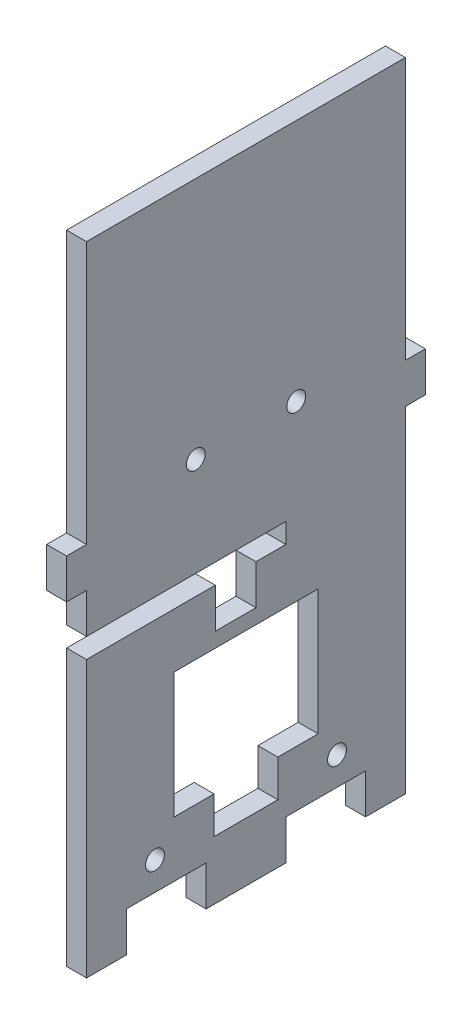
from build123d import *

# Parameters (mm, degrees)
SKETCH1_W              = 273.05
SKETCH1_H              = 139.7
BOSS_EXTRUDE1_DEPTH    = 6.35
SKETCH2_W              = 273.05
SKETCH2_H              = 139.7
SKETCH2_W_2            = 266.7
SKETCH2_H_2            = 133.35
BOSS_EXTRUDE2_DEPTH    = 298.45
SKETCH3_W              = 6.35
SKETCH3_H              = 16.933333333
SKETCH3_H_2            = 16.933333334
DOOR_SLOT_DEPTH        = 12.7
DOOR_GUIDE_HOLES_REACH = 362.806
SKETCH4_W              = 6.35
SKETCH4_H              = 15.875
LEVER_HOLES_W          = 9.652
LEVER_HOLES_H          = 6.35
LEVER_HOLES_W_2        = 6.35
CUT_EXTRUDE1_DEPTH     = 363.019620497
CUT_EXTRUDE3_REACH     = 417.137
SKETCH8_R              = 3.175
SKETCH16_W             = 329.651778096
SKETCH16_H             = 315.233565403
CUT_EXTRUDE10_DEPTH    = 363.019620497
LEFT_RIGHT_W           = 9.525
LEFT_RIGHT_H           = 6.35
LEFT_RIGHT_W_2         = 12.7
LEFT_RIGHT_W_3         = 3.175
LEFT_RIGHT_H_2         = 12.7
CUT_EXTRUDE11_DEPTH    = 416.136561869
SKETCH17_W             = 23
SKETCH17_H             = 20.0007988
SKETCH17_W_2           = 10.16
SKETCH17_H_2           = 5.89
SKETCH17_R             = 1.5
CUT_EXTRUDE12_DEPTH    = 313.717353412
CUT_EXTRUDE13_DEPTH    = 313.717353412
CUT_EXTRUDE14_DEPTH    = 106.589636092


with BuildPart() as part:
    # Sketch1 → Boss-Extrude1 (new body)
    with BuildSketch(Plane(origin=(0, 0, 0), x_dir=(1, 0, 0), z_dir=(0, 1, 0))):
        Rectangle(SKETCH1_W, SKETCH1_H)
    extrude(amount=BOSS_EXTRUDE1_DEPTH)

    # Sketch2 → Boss-Extrude2 (add)
    with BuildSketch(Plane(origin=(0, 6.35, 0), x_dir=(1, 0, 0), z_dir=(0, 1, 0))):
        Rectangle(SKETCH2_W, SKETCH2_H)
        Rectangle(SKETCH2_W_2, SKETCH2_H_2, mode=Mode.SUBTRACT)
    extrude(amount=BOSS_EXTRUDE2_DEPTH)

    # Sketch3 → Door Slot (cut)
    with BuildSketch(Plane.XY.offset(69.85)):
        with BuildLine():
            Line((-31.75, 283.21), (-31.75, 6.35))
            Line((-31.75, 6.35), (-25.146, 6.35))
            Line((-25.146, 6.35), (-25.146, 292.354))
            Line((-25.146, 292.354), (-44.704, 292.354))
            Line((-44.704, 292.354), (-44.704, 285.75))
            Line((-44.704, 285.75), (-34.29, 285.75))
            ThreePointArc((-34.29, 285.75), (-32.493948776, 285.006051224), (-31.75, 283.21))
        make_face()
        with Locations((-15.621, 80.433333334)):
            Rectangle(SKETCH3_W, SKETCH3_H)
        with Locations((-15.621, 50.8)):
            Rectangle(SKETCH3_W, SKETCH3_H_2)
        with Locations((-15.621, 21.166666667)):
            Rectangle(SKETCH3_W, SKETCH3_H)
    extrude(amount=-DOOR_SLOT_DEPTH, mode=Mode.SUBTRACT)

    # Sketch4 → Door Guide Holes (cut, up to next)
    with BuildSketch(Plane.XY.offset(-66.675), mode=Mode.PRIVATE) as door_guide_holes_sk1:
        with Locations((-47.879, 284.1625)):
            Rectangle(SKETCH4_W, SKETCH4_H)
    door_guide_holes_tool1 = extrude(door_guide_holes_sk1.sketch, amount=-DOOR_GUIDE_HOLES_REACH, mode=Mode.PRIVATE) & part.part
    # Sketch4 → Door Guide Holes (cut, up to next)
    with BuildSketch(Plane.XY.offset(-66.675), mode=Mode.PRIVATE) as door_guide_holes_sk2:
        with Locations((-47.879, 255.5875)):
            Rectangle(SKETCH4_W, SKETCH4_H)
    door_guide_holes_tool2 = extrude(door_guide_holes_sk2.sketch, amount=-DOOR_GUIDE_HOLES_REACH, mode=Mode.PRIVATE) & part.part
    # Sketch4 → Door Guide Holes (cut, up to next)
    with BuildSketch(Plane.XY.offset(-66.675), mode=Mode.PRIVATE) as door_guide_holes_sk3:
        with Locations((-47.879, 227.0125)):
            Rectangle(SKETCH4_W, SKETCH4_H)
    door_guide_holes_tool3 = extrude(door_guide_holes_sk3.sketch, amount=-DOOR_GUIDE_HOLES_REACH, mode=Mode.PRIVATE) & part.part
    # Sketch4 → Door Guide Holes (cut, up to next)
    with BuildSketch(Plane.XY.offset(-66.675), mode=Mode.PRIVATE) as door_guide_holes_sk4:
        with Locations((-47.879, 198.4375)):
            Rectangle(SKETCH4_W, SKETCH4_H)
    door_guide_holes_tool4 = extrude(door_guide_holes_sk4.sketch, amount=-DOOR_GUIDE_HOLES_REACH, mode=Mode.PRIVATE) & part.part
    # Sketch4 → Door Guide Holes (cut, up to next)
    with BuildSketch(Plane.XY.offset(-66.675), mode=Mode.PRIVATE) as door_guide_holes_sk5:
        with Locations((-47.879, 169.8625)):
            Rectangle(SKETCH4_W, SKETCH4_H)
    door_guide_holes_tool5 = extrude(door_guide_holes_sk5.sketch, amount=-DOOR_GUIDE_HOLES_REACH, mode=Mode.PRIVATE) & part.part
    # Sketch4 → Door Guide Holes (cut, up to next)
    with BuildSketch(Plane.XY.offset(-66.675), mode=Mode.PRIVATE) as door_guide_holes_sk6:
        with Locations((-47.879, 141.2875)):
            Rectangle(SKETCH4_W, SKETCH4_H)
    door_guide_holes_tool6 = extrude(door_guide_holes_sk6.sketch, amount=-DOOR_GUIDE_HOLES_REACH, mode=Mode.PRIVATE) & part.part
    # Sketch4 → Door Guide Holes (cut, up to next)
    with BuildSketch(Plane.XY.offset(-66.675), mode=Mode.PRIVATE) as door_guide_holes_sk7:
        with Locations((-47.879, 112.7125)):
            Rectangle(SKETCH4_W, SKETCH4_H)
    door_guide_holes_tool7 = extrude(door_guide_holes_sk7.sketch, amount=-DOOR_GUIDE_HOLES_REACH, mode=Mode.PRIVATE) & part.part
    # Sketch4 → Door Guide Holes (cut, up to next)
    with BuildSketch(Plane.XY.offset(-66.675), mode=Mode.PRIVATE) as door_guide_holes_sk8:
        with Locations((-47.879, 84.1375)):
            Rectangle(SKETCH4_W, SKETCH4_H)
    door_guide_holes_tool8 = extrude(door_guide_holes_sk8.sketch, amount=-DOOR_GUIDE_HOLES_REACH, mode=Mode.PRIVATE) & part.part
    # Sketch4 → Door Guide Holes (cut, up to next)
    with BuildSketch(Plane.XY.offset(-66.675), mode=Mode.PRIVATE) as door_guide_holes_sk9:
        with Locations((-47.879, 55.5625)):
            Rectangle(SKETCH4_W, SKETCH4_H)
    door_guide_holes_tool9 = extrude(door_guide_holes_sk9.sketch, amount=-DOOR_GUIDE_HOLES_REACH, mode=Mode.PRIVATE) & part.part
    # Sketch4 → Door Guide Holes (cut, up to next)
    with BuildSketch(Plane.XY.offset(-66.675), mode=Mode.PRIVATE) as door_guide_holes_sk10:
        with Locations((-47.879, 26.9875)):
            Rectangle(SKETCH4_W, SKETCH4_H)
    door_guide_holes_tool10 = extrude(door_guide_holes_sk10.sketch, amount=-DOOR_GUIDE_HOLES_REACH, mode=Mode.PRIVATE) & part.part
    door_guide_holes_1 = door_guide_holes_tool1.solids().sort_by_distance((-47.879, 284.1625, -66.675))[0]
    add(door_guide_holes_1, mode=Mode.SUBTRACT)
    door_guide_holes_2 = door_guide_holes_tool2.solids().sort_by_distance((-47.879, 255.5875, -66.675))[0]
    add(door_guide_holes_2, mode=Mode.SUBTRACT)
    door_guide_holes_3 = door_guide_holes_tool3.solids().sort_by_distance((-47.879, 227.0125, -66.675))[0]
    add(door_guide_holes_3, mode=Mode.SUBTRACT)
    door_guide_holes_4 = door_guide_holes_tool4.solids().sort_by_distance((-47.879, 198.4375, -66.675))[0]
    add(door_guide_holes_4, mode=Mode.SUBTRACT)
    door_guide_holes_5 = door_guide_holes_tool5.solids().sort_by_distance((-47.879, 169.8625, -66.675))[0]
    add(door_guide_holes_5, mode=Mode.SUBTRACT)
    door_guide_holes_6 = door_guide_holes_tool6.solids().sort_by_distance((-47.879, 141.2875, -66.675))[0]
    add(door_guide_holes_6, mode=Mode.SUBTRACT)
    door_guide_holes_7 = door_guide_holes_tool7.solids().sort_by_distance((-47.879, 112.7125, -66.675))[0]
    add(door_guide_holes_7, mode=Mode.SUBTRACT)
    door_guide_holes_8 = door_guide_holes_tool8.solids().sort_by_distance((-47.879, 84.1375, -66.675))[0]
    add(door_guide_holes_8, mode=Mode.SUBTRACT)
    door_guide_holes_9 = door_guide_holes_tool9.solids().sort_by_distance((-47.879, 55.5625, -66.675))[0]
    add(door_guide_holes_9, mode=Mode.SUBTRACT)
    door_guide_holes_10 = door_guide_holes_tool10.solids().sort_by_distance((-47.879, 26.9875, -66.675))[0]
    add(door_guide_holes_10, mode=Mode.SUBTRACT)
    door_guide_holes = door_guide_holes_1 + door_guide_holes_2 + door_guide_holes_3 + door_guide_holes_4 + door_guide_holes_5 + door_guide_holes_6 + door_guide_holes_7 + door_guide_holes_8 + door_guide_holes_9 + door_guide_holes_10  # Door Guide Holes as one shape, for the pattern or mirror that repeats it

    # Mirror1: Door Guide Holes across plane
    add(door_guide_holes.mirror(Plane.ZY.offset(34.925)), mode=Mode.SUBTRACT)

    # Lever Holes → Cut-Extrude1 (cut, through all)
    with BuildSketch(Plane.XY.offset(69.85)):
        with Locations((54.102, 28.575)):
            Rectangle(LEVER_HOLES_W, LEVER_HOLES_H)
        with Locations((39.3065, 15.875)):
            Rectangle(LEVER_HOLES_W_2, LEVER_HOLES_H)
        with Locations((68.8975, 15.875)):
            Rectangle(LEVER_HOLES_W_2, LEVER_HOLES_H)
    extrude(amount=-CUT_EXTRUDE1_DEPTH, mode=Mode.SUBTRACT)

    # Sketch8 → Cut-Extrude3 (cut, up to next)
    with BuildSketch(Plane.ZY.offset(136.525), mode=Mode.PRIVATE) as cut_extrude3_sk1:
        with Locations((0, 19.05)):
            Circle(SKETCH8_R)
    cut_extrude3_tool1 = extrude(cut_extrude3_sk1.sketch, amount=-CUT_EXTRUDE3_REACH, mode=Mode.PRIVATE) & part.part
    add(cut_extrude3_tool1.solids().sort_by_distance((-136.525, 19.05, 0))[0], mode=Mode.SUBTRACT)

    # Sketch16 → Cut-Extrude10 (cut, through all)
    with BuildSketch(Plane.XY.offset(69.85)):
        with Locations((-31.475889048, 147.183217299)):
            Rectangle(SKETCH16_W, SKETCH16_H)
    extrude(amount=-CUT_EXTRUDE10_DEPTH, mode=Mode.SUBTRACT)

    # Left/Right → Cut-Extrude11 (cut, through all)
    with BuildSketch(Plane.ZY.offset(136.525)):
        with Locations((61.9125, 3.175)):
            Rectangle(LEFT_RIGHT_W, LEFT_RIGHT_H)
        with Locations((38.1, 3.175)):
            Rectangle(LEFT_RIGHT_W_2, LEFT_RIGHT_H)
        with Locations((68.2625, 19.05)):
            Rectangle(LEFT_RIGHT_W_3, LEFT_RIGHT_H_2)
        with Locations((12.7, 3.175)):
            Rectangle(LEFT_RIGHT_W_2, LEFT_RIGHT_H)
        with Locations((68.2625, 44.45)):
            Rectangle(LEFT_RIGHT_W_3, LEFT_RIGHT_H_2)
        with Locations((-12.7, 3.175)):
            Rectangle(LEFT_RIGHT_W_2, LEFT_RIGHT_H)
        with Locations((68.2625, 69.85)):
            Rectangle(LEFT_RIGHT_W_3, LEFT_RIGHT_H_2)
        with Locations((-38.1, 3.175)):
            Rectangle(LEFT_RIGHT_W_2, LEFT_RIGHT_H)
        with Locations((68.2625, 95.25)):
            Rectangle(LEFT_RIGHT_W_3, LEFT_RIGHT_H_2)
        with Locations((-61.9125, 3.175)):
            Rectangle(LEFT_RIGHT_W, LEFT_RIGHT_H)
        with Locations((68.2625, 120.65)):
            Rectangle(LEFT_RIGHT_W_3, LEFT_RIGHT_H_2)
        with Locations((-68.2625, 19.05)):
            Rectangle(LEFT_RIGHT_W_3, LEFT_RIGHT_H_2)
        with Locations((68.2625, 146.05)):
            Rectangle(LEFT_RIGHT_W_3, LEFT_RIGHT_H_2)
        with Locations((-68.2625, 44.45)):
            Rectangle(LEFT_RIGHT_W_3, LEFT_RIGHT_H_2)
        with Locations((68.2625, 171.45)):
            Rectangle(LEFT_RIGHT_W_3, LEFT_RIGHT_H_2)
        with Locations((-68.2625, 69.85)):
            Rectangle(LEFT_RIGHT_W_3, LEFT_RIGHT_H_2)
        with Locations((68.2625, 196.85)):
            Rectangle(LEFT_RIGHT_W_3, LEFT_RIGHT_H_2)
        with Locations((-68.2625, 95.25)):
            Rectangle(LEFT_RIGHT_W_3, LEFT_RIGHT_H_2)
        with Locations((68.2625, 222.25)):
            Rectangle(LEFT_RIGHT_W_3, LEFT_RIGHT_H_2)
        with Locations((-68.2625, 120.65)):
            Rectangle(LEFT_RIGHT_W_3, LEFT_RIGHT_H_2)
        with Locations((68.2625, 247.65)):
            Rectangle(LEFT_RIGHT_W_3, LEFT_RIGHT_H_2)
        with Locations((-68.2625, 146.05)):
            Rectangle(LEFT_RIGHT_W_3, LEFT_RIGHT_H_2)
        with Locations((68.2625, 273.05)):
            Rectangle(LEFT_RIGHT_W_3, LEFT_RIGHT_H_2)
        with Locations((-68.2625, 171.45)):
            Rectangle(LEFT_RIGHT_W_3, LEFT_RIGHT_H_2)
        with Locations((68.2625, 298.45)):
            Rectangle(LEFT_RIGHT_W_3, LEFT_RIGHT_H_2)
        with Locations((-68.2625, 196.85)):
            Rectangle(LEFT_RIGHT_W_3, LEFT_RIGHT_H_2)
        with Locations((-68.2625, 222.25)):
            Rectangle(LEFT_RIGHT_W_3, LEFT_RIGHT_H_2)
        with Locations((-68.2625, 247.65)):
            Rectangle(LEFT_RIGHT_W_3, LEFT_RIGHT_H_2)
        with Locations((-68.2625, 273.05)):
            Rectangle(LEFT_RIGHT_W_3, LEFT_RIGHT_H_2)
        with Locations((-68.2625, 298.45)):
            Rectangle(LEFT_RIGHT_W_3, LEFT_RIGHT_H_2)
    extrude(amount=-CUT_EXTRUDE11_DEPTH, mode=Mode.SUBTRACT)

    # Sketch17 → Cut-Extrude12 (cut, through all)
    with BuildSketch(Plane(origin=(136.525, 0, 0), x_dir=(0, 0, -1), z_dir=(1, 0, 0))):
        with Locations((0, 25.2403994)):
            Rectangle(SKETCH17_W, SKETCH17_H)
        with Locations((0, 12.295)):
            Rectangle(SKETCH17_W_2, SKETCH17_H_2)
        with Locations((14.5, 10.85)):
            Circle(SKETCH17_R)
        with Locations((-14.5, 10.85)):
            Circle(SKETCH17_R)
        with Locations((-8, 62.8499886)):
            Circle(SKETCH17_R)
        with Locations((8, 62.8499886)):
            Circle(SKETCH17_R)
    extrude(amount=-CUT_EXTRUDE12_DEPTH, mode=Mode.SUBTRACT)

    # Sketch18 → Cut-Extrude13 (cut, through all)
    with BuildSketch(Plane(origin=(136.525, 0, 0), x_dir=(0, 0, -1), z_dir=(1, 0, 0))):
        Polygon((-69.85, 304.8), (-69.85, 0), (-25.4, 0), (-25.4, 53.467), (-28.575, 53.467), (-28.575, 59.817), (-25.4, 59.817), (-25.4, 101.6), (25.4, 101.6), (25.4, 59.817), (28.575, 59.817), (28.575, 53.467), (25.4, 53.467), (25.4, 0), (69.85, 0), (69.85, 304.8), align=None)
    extrude(amount=-CUT_EXTRUDE13_DEPTH, mode=Mode.SUBTRACT)

    # Sketch19 → Cut-Extrude14 (cut, through all)
    with BuildSketch(Plane.ZY.offset(-133.35)):
        Polygon((25.4, 47.117), (-6.35, 47.117), (-6.35, 43.942), (-1.5875, 43.942), (-1.5875, 37.592), (4.8895, 37.592), (4.8895, 43.942), (25.4, 43.942), align=None)
    extrude(amount=-CUT_EXTRUDE14_DEPTH, mode=Mode.SUBTRACT)


solid = part.part
